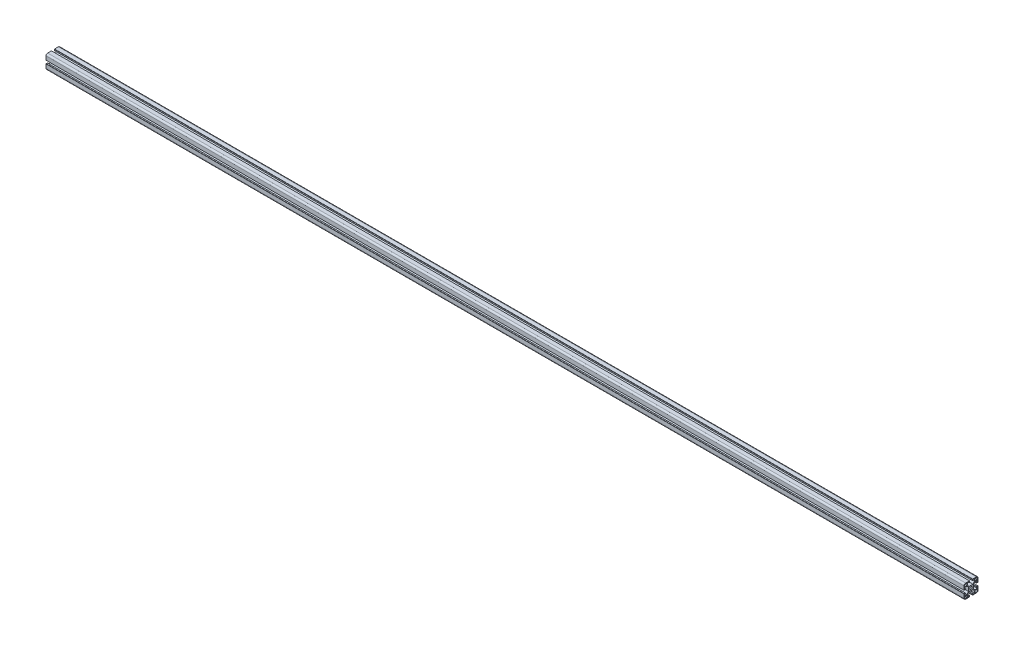
from build123d import *

# Parameters (mm, degrees)
SKETCH_3_R          = 3.4
EXTRUDE_1_DEPTH     = 2622
CUT_EXTRUDE_3_DEPTH = 3297


with BuildPart() as part:
    # 草图3 → 凸台-拉伸1 (new body)
    with BuildSketch(Plane(origin=(0, 0, 0), x_dir=(0, 0, -1), z_dir=(1, 0, 0))):
        with BuildLine():
            Line((-15.5, -20), (-4.5, -20))
            Line((-4.5, -20), (-4.5, -19.5))
            Line((-4.5, -19.5), (-4.1, -19.5))
            Line((-4.1, -19.5), (-4.1, -16.2))
            Line((-4.1, -16.2), (-6.4, -16.2))
            Line((-6.4, -16.2), (-6.4, -18.2))
            Line((-6.4, -18.2), (-10.25, -18.2))
            Line((-10.25, -18.2), (-10.25, -11.522792206))
            Line((-10.25, -11.522792206), (-5.479130441, -6.751922647))
            Line((-5.479130441, -6.751922647), (5.479130441, -6.751922647))
            Line((5.479130441, -6.751922647), (10.25, -11.522792206))
            Line((10.25, -11.522792206), (10.25, -18.2))
            Line((10.25, -18.2), (6.4, -18.2))
            Line((6.4, -18.2), (6.4, -16.2))
            Line((6.4, -16.2), (4.1, -16.2))
            Line((4.1, -16.2), (4.1, -19.5))
            Line((4.1, -19.5), (4.5, -19.5))
            Line((4.5, -19.5), (4.5, -20))
            Line((4.5, -20), (15.5, -20))
            ThreePointArc((15.5, -20), (18.681980515, -18.681980515), (20, -15.5))
            Line((20, -15.5), (20, -4.5))
            Line((20, -4.5), (19.5, -4.5))
            Line((19.5, -4.5), (19.5, -4.1))
            Line((19.5, -4.1), (16.2, -4.1))
            Line((16.2, -4.1), (16.2, -6.4))
            Line((16.2, -6.4), (18.2, -6.4))
            Line((18.2, -6.4), (18.2, -10.25))
            Line((18.2, -10.25), (11.522792206, -10.25))
            Line((11.522792206, -10.25), (6.751922647, -5.479130441))
            Line((6.751922647, -5.479130441), (6.751922647, 5.479130441))
            Line((6.751922647, 5.479130441), (11.522792206, 10.25))
            Line((11.522792206, 10.25), (18.2, 10.25))
            Line((18.2, 10.25), (18.2, 6.4))
            Line((18.2, 6.4), (16.2, 6.4))
            Line((16.2, 6.4), (16.2, 4.1))
            Line((16.2, 4.1), (19.5, 4.1))
            Line((19.5, 4.1), (19.5, 4.5))
            Line((19.5, 4.5), (20, 4.5))
            Line((20, 4.5), (20, 15.5))
            ThreePointArc((20, 15.5), (18.681980515, 18.681980515), (15.5, 20))
            Line((15.5, 20), (4.5, 20))
            Line((4.5, 20), (4.5, 19.5))
            Line((4.5, 19.5), (4.1, 19.5))
            Line((4.1, 19.5), (4.1, 16.2))
            Line((4.1, 16.2), (6.4, 16.2))
            Line((6.4, 16.2), (6.4, 18.2))
            Line((6.4, 18.2), (10.25, 18.2))
            Line((10.25, 18.2), (10.25, 11.522792206))
            Line((10.25, 11.522792206), (5.479130441, 6.751922647))
            Line((5.479130441, 6.751922647), (-5.479130441, 6.751922647))
            Line((-5.479130441, 6.751922647), (-10.25, 11.522792206))
            Line((-10.25, 11.522792206), (-10.25, 18.2))
            Line((-10.25, 18.2), (-6.4, 18.2))
            Line((-6.4, 18.2), (-6.4, 16.2))
            Line((-6.4, 16.2), (-4.1, 16.2))
            Line((-4.1, 16.2), (-4.1, 19.5))
            Line((-4.1, 19.5), (-4.5, 19.5))
            Line((-4.5, 19.5), (-4.5, 20))
            Line((-4.5, 20), (-15.5, 20))
            ThreePointArc((-15.5, 20), (-18.681980515, 18.681980515), (-20, 15.5))
            Line((-20, 15.5), (-20, 4.5))
            Line((-20, 4.5), (-19.5, 4.5))
            Line((-19.5, 4.5), (-19.5, 4.1))
            Line((-19.5, 4.1), (-16.2, 4.1))
            Line((-16.2, 4.1), (-16.2, 6.4))
            Line((-16.2, 6.4), (-18.2, 6.4))
            Line((-18.2, 6.4), (-18.2, 10.25))
            Line((-18.2, 10.25), (-11.522792206, 10.25))
            Line((-11.522792206, 10.25), (-6.751922647, 5.479130441))
            Line((-6.751922647, 5.479130441), (-6.751922647, -5.479130441))
            Line((-6.751922647, -5.479130441), (-11.522792206, -10.25))
            Line((-11.522792206, -10.25), (-18.2, -10.25))
            Line((-18.2, -10.25), (-18.2, -6.4))
            Line((-18.2, -6.4), (-16.2, -6.4))
            Line((-16.2, -6.4), (-16.2, -4.1))
            Line((-16.2, -4.1), (-19.5, -4.1))
            Line((-19.5, -4.1), (-19.5, -4.5))
            Line((-19.5, -4.5), (-20, -4.5))
            Line((-20, -4.5), (-20, -15.5))
            ThreePointArc((-20, -15.5), (-18.681980515, -18.681980515), (-15.5, -20))
        make_face()
        Circle(SKETCH_3_R, mode=Mode.SUBTRACT)
    extrude(amount=EXTRUDE_1_DEPTH)

    # 草图4 → 切除-拉伸3 (cut)
    with BuildSketch(Plane(origin=(2622, -20, 15.5), x_dir=(0, 0, 1), z_dir=(-1, 0, 0))):
        with BuildLine():
            Line((-3.75, 31.75), (3, 31.75))
            Line((3, 31.75), (3, 35.5))
            ThreePointArc((3, 35.5), (2.121320344, 37.621320344), (0, 38.5))
            Line((0, 38.5), (-3.75, 38.5))
            Line((-3.75, 38.5), (-3.75, 31.75))
        make_face()
        with BuildLine():
            Line((-3.75, 8.25), (-3.75, 1.5))
            Line((-3.75, 1.5), (0, 1.5))
            ThreePointArc((0, 1.5), (2.121320344, 2.378679656), (3, 4.5))
            Line((3, 4.5), (3, 8.25))
            Line((3, 8.25), (-3.75, 8.25))
        make_face()
        with BuildLine():
            Line((-27.25, 8.25), (-34, 8.25))
            Line((-34, 8.25), (-34, 4.5))
            ThreePointArc((-34, 4.5), (-33.121320344, 2.378679656), (-31, 1.5))
            Line((-31, 1.5), (-27.25, 1.5))
            Line((-27.25, 1.5), (-27.25, 8.25))
        make_face()
        with BuildLine():
            Line((-27.25, 31.75), (-27.25, 38.5))
            Line((-27.25, 38.5), (-31, 38.5))
            ThreePointArc((-31, 38.5), (-33.121320344, 37.621320344), (-34, 35.5))
            Line((-34, 35.5), (-34, 31.75))
            Line((-34, 31.75), (-27.25, 31.75))
        make_face()
    extrude(amount=CUT_EXTRUDE_3_DEPTH, mode=Mode.SUBTRACT)


solid = part.part
